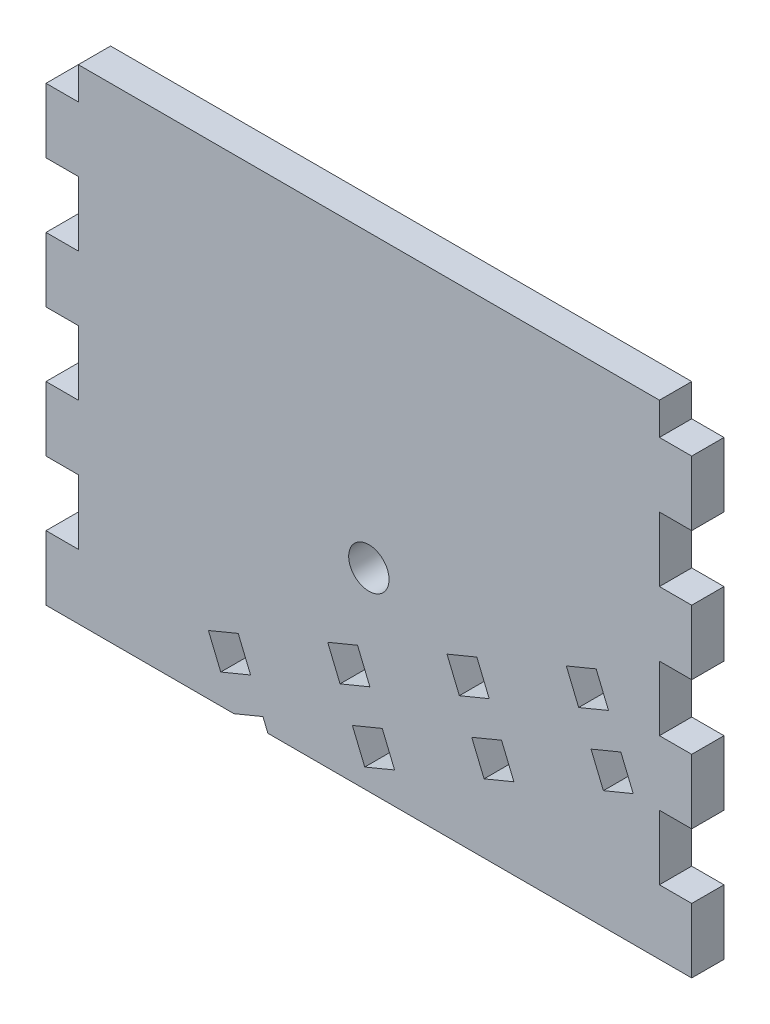
from build123d import *

# Parameters (mm, degrees)
SKETCH1_W           = 127
SKETCH1_H           = 95.25
BOSS_EXTRUDE1_DEPTH = 6.35
SKETCH2_R           = 3.96875
CUT_EXTRUDE1_DEPTH  = 7.35
SKETCH3_W           = 6.35
SKETCH3_H           = 12.7
CUT_EXTRUDE2_DEPTH  = 7.35
SKETCH4_W           = 6.35
SKETCH4_H           = 12.7
CUT_EXTRUDE3_DEPTH  = 7.35
LPATTERN1_COUNT     = 4
LPATTERN1_PITCH     = 25.4
CUT_EXTRUDE4_DEPTH  = 7.35
LPATTERN2_COUNT     = 4
LPATTERN2_PITCH     = 25.4


with BuildPart() as part:
    # Sketch1 → Boss-Extrude1 (new body)
    with BuildSketch(Plane.XY):
        with Locations((63.5, 47.625)):
            Rectangle(SKETCH1_W, SKETCH1_H)
    extrude(amount=BOSS_EXTRUDE1_DEPTH)

    # Sketch2 → Cut-Extrude1 (cut, through all)
    with BuildSketch(Plane.XY.offset(6.35)):
        with Locations((63.5, 38.1)):
            Circle(SKETCH2_R)
    extrude(amount=-CUT_EXTRUDE1_DEPTH, mode=Mode.SUBTRACT)

    # Sketch3 → Cut-Extrude2 (cut, through all)
    with BuildSketch(Plane.XY.offset(6.35)):
        with Locations((3.175, 19.05)):
            Rectangle(SKETCH3_W, SKETCH3_H)
    cut_extrude2 = extrude(amount=-CUT_EXTRUDE2_DEPTH, mode=Mode.SUBTRACT)

    # Sketch4 → Cut-Extrude3 (cut, through all)
    with BuildSketch(Plane.XY.offset(6.35)):
        with Locations((123.825, 19.05)):
            Rectangle(SKETCH4_W, SKETCH4_H)
    cut_extrude3 = extrude(amount=-CUT_EXTRUDE3_DEPTH, mode=Mode.SUBTRACT)

    # LPattern1: Cut-Extrude2, Cut-Extrude3 ×4
    with Locations(*[(0, i * LPATTERN1_PITCH, 0) for i in range(1, LPATTERN1_COUNT)]):
        add(cut_extrude2, mode=Mode.SUBTRACT)
        add(cut_extrude3, mode=Mode.SUBTRACT)

    # Sketch5 → Cut-Extrude4 (cut, through all)
    with BuildSketch(Plane.XY.offset(6.35)):
        Polygon((102.338352728, 40.824853058), (104.768392524, 34.958218027), (110.635027555, 37.388257822), (108.20498776, 43.254892854), align=None)
        Polygon((109.628472115, 23.224947964), (107.198432319, 29.091582995), (113.065067351, 31.521622791), (115.495107146, 25.65498776), align=None)
    cut_extrude4 = extrude(amount=-CUT_EXTRUDE4_DEPTH, mode=Mode.SUBTRACT)

    # LPattern2: Cut-Extrude4 ×4
    with Locations(*[Vector(-0.923879533, -0.382683432, 0) * (i * LPATTERN2_PITCH) for i in range(1, LPATTERN2_COUNT)]):
        add(cut_extrude4, mode=Mode.SUBTRACT)


solid = part.part
